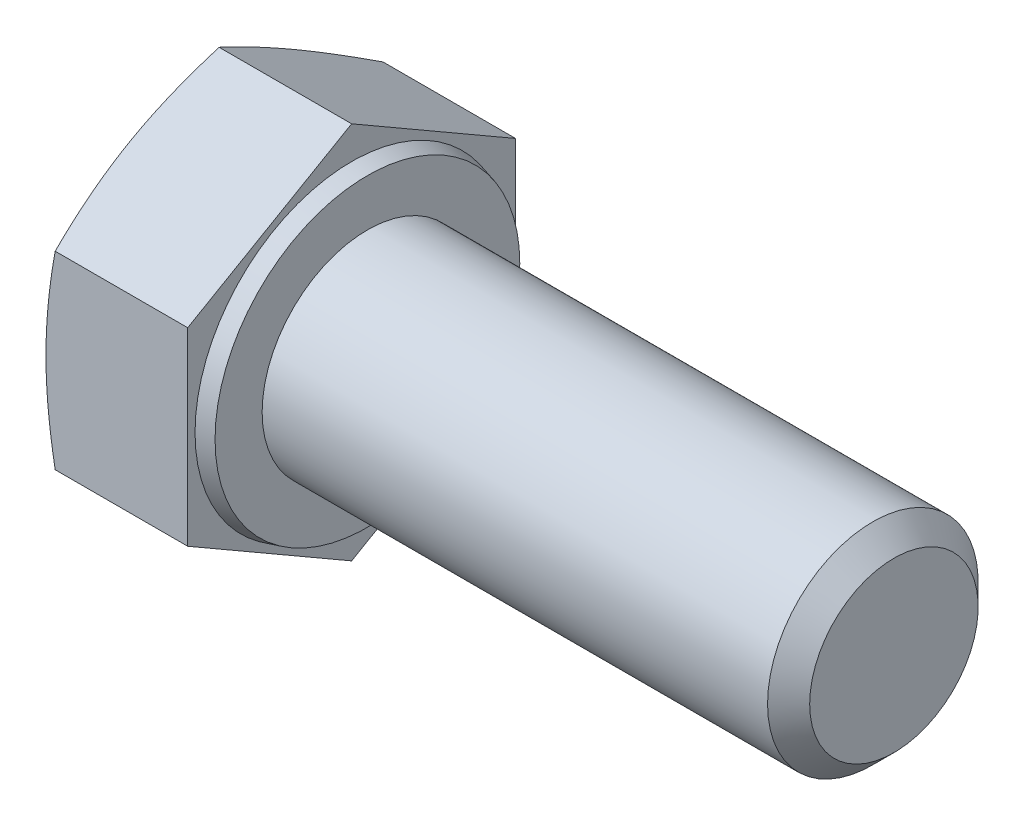
from build123d import *

# Parameters (mm, degrees)
SKETCH_2_OUTSIDE_W  = 22.99
SKETCH_2_OUTSIDE_H  = 22.99
CUT_EXTRUDE_1_DEPTH = 28.964168144
CHAMFER_1_SIZE      = 0.8


with BuildPart() as part:
    # Эскиз1 → Повернуть1 (revolve)
    with BuildSketch(Plane.XY, mode=Mode.PRIVATE) as revolve_1_sk:
        Polygon((-5.45, 0), (-5.45, 7.19), (0, 7.19), (0, 5.948974596), (0.6, 5.788205081), (0.6, 4), (20.6, 4), (20.6, 0), align=None)
    revolve(revolve_1_sk.sketch.rotate(Axis((-1000, 0, 0), (1, 0, 0)), 90), axis=Axis((-1000, 0, 0), (1, 0, 0)))

    # Эскиз2 outside → Вырез-Вытянуть1 (cut, through all)
    with BuildSketch(Plane.ZY.offset(5.45)):
        Rectangle(SKETCH_2_OUTSIDE_W, SKETCH_2_OUTSIDE_H)
        Polygon((0, -7.19), (6.226722653, -3.595), (6.226722653, 3.595), (0, 7.19), (-6.226722653, 3.595), (-6.226722653, -3.595), align=None, mode=Mode.SUBTRACT)
    extrude(amount=-CUT_EXTRUDE_1_DEPTH, mode=Mode.SUBTRACT)

    # Эскиз4 → Вырез-Повернуть1 (revolve, cut)
    with BuildSketch(Plane.XY, mode=Mode.PRIVATE) as cut_revolve_1_sk:
        Polygon((-5.45, 6.04675), (-5.03389103, 7.19), (-5.45, 7.19), align=None)
    revolve(cut_revolve_1_sk.sketch.rotate(Axis((-1000, 0, 0), (1, 0, 0)), 299.999999983), axis=Axis((-1000, 0, 0), (1, 0, 0)), mode=Mode.SUBTRACT)

    # Фаска1
    chamfer_1_edges = [part.edges().sort_by_distance(p)[0] for p in [
        (20.6, 0, -4),
    ]]
    chamfer(chamfer_1_edges, length=CHAMFER_1_SIZE)


solid = part.part
